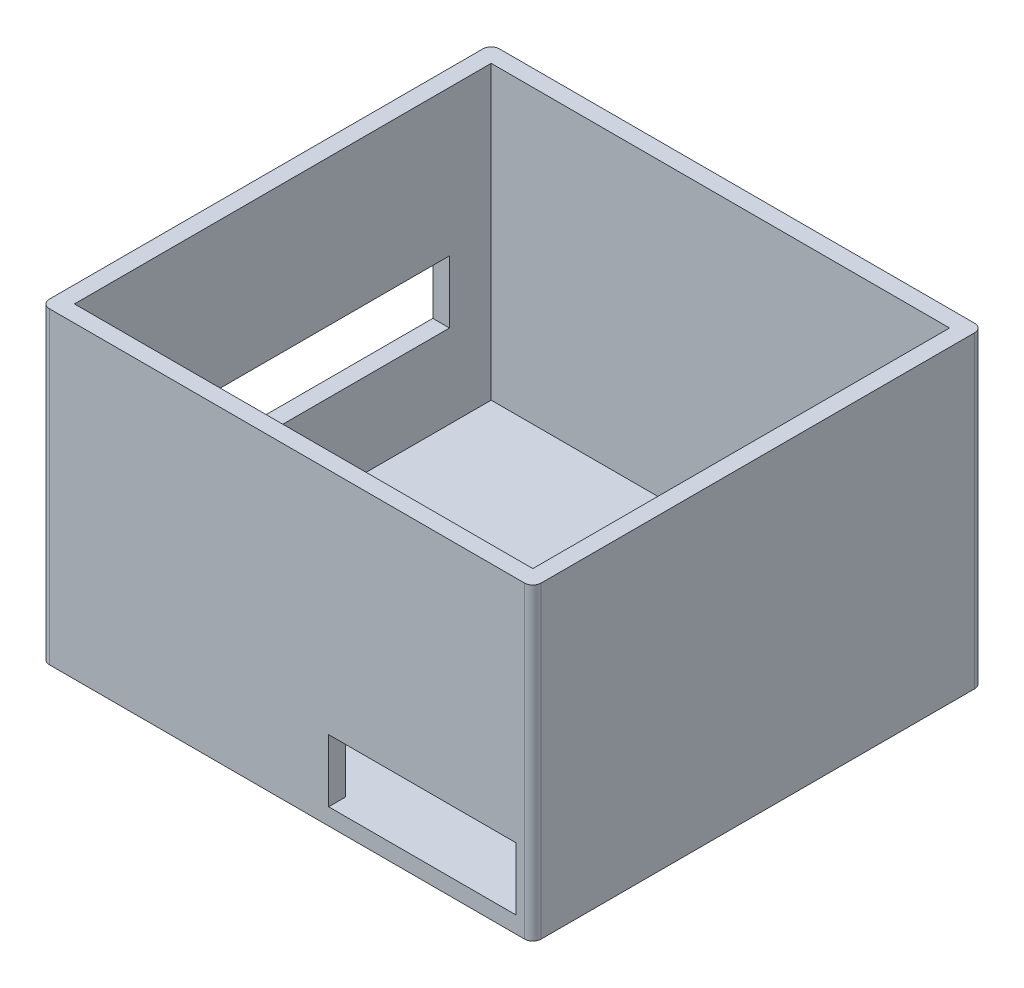
from build123d import *

# Parameters (mm, degrees)
SKETCH1_W           = 118
SKETCH1_H           = 108
BOSS_EXTRUDE1_DEPTH = 4
SKETCH2_W           = 118
SKETCH2_H           = 108
SKETCH2_W_2         = 110
SKETCH2_H_2         = 100
BOSS_EXTRUDE2_DEPTH = 70
SKETCH3_W           = 80
SKETCH3_H           = 15
CUT_EXTRUDE1_DEPTH  = 4
SKETCH4_W           = 45
SKETCH4_H           = 15
CUT_EXTRUDE2_DEPTH  = 4
FILLET1_R           = 2


with BuildPart() as part:
    # Sketch1 → Boss-Extrude1 (new body)
    with BuildSketch(Plane(origin=(0, 0, 0), x_dir=(1, 0, 0), z_dir=(0, 1, 0))):
        with Locations((59, 54)):
            Rectangle(SKETCH1_W, SKETCH1_H)
    extrude(amount=BOSS_EXTRUDE1_DEPTH)

    # Sketch2 → Boss-Extrude2 (add)
    with BuildSketch(Plane(origin=(0, 4, 0), x_dir=(1, 0, 0), z_dir=(0, 1, 0))):
        with Locations((59, 54)):
            Rectangle(SKETCH2_W, SKETCH2_H)
        with Locations((59, 54)):
            Rectangle(SKETCH2_W_2, SKETCH2_H_2, mode=Mode.SUBTRACT)
    extrude(amount=BOSS_EXTRUDE2_DEPTH)

    # Sketch3 → Cut-Extrude1 (cut)
    with BuildSketch(Plane.ZY):
        with Locations((-54, 31.5)):
            Rectangle(SKETCH3_W, SKETCH3_H)
    extrude(amount=-CUT_EXTRUDE1_DEPTH, mode=Mode.SUBTRACT)

    # Sketch4 → Cut-Extrude2 (cut)
    with BuildSketch(Plane.XY):
        with Locations((91.5, 11.5)):
            Rectangle(SKETCH4_W, SKETCH4_H)
    extrude(amount=-CUT_EXTRUDE2_DEPTH, mode=Mode.SUBTRACT)

    # Fillet1
    fillet1_edges = [part.edges().sort_by_distance(p)[0] for p in [
        (0, 37, -108),
        (118, 37, -108),
        (118, 37, 0),
        (0, 37, 0),
    ]]
    fillet(fillet1_edges, radius=FILLET1_R)


solid = part.part
